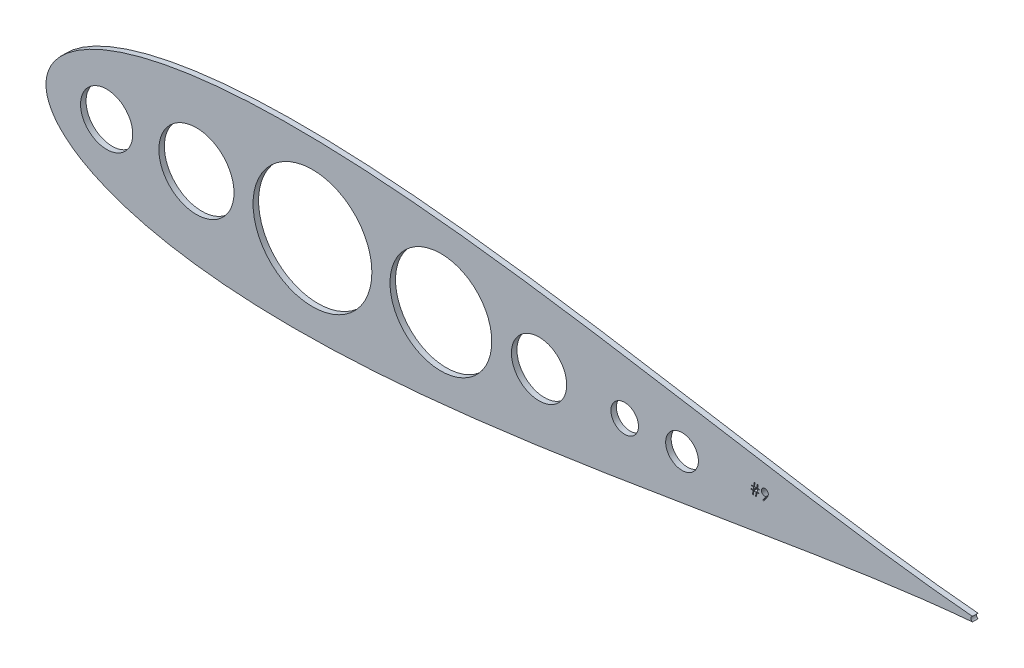
from build123d import *

# Parameters (mm, degrees)
SKETCH2_R           = 12.003328726
SKETCH2_R_2         = 17.272
SKETCH2_R_3         = 27.304154698
SKETCH2_R_4         = 12.7
SKETCH2_R_5         = 7.526838105
SKETCH2_R_6         = 23.387800821
SKETCH2_R_7         = 6.35
BOSS_EXTRUDE1_DEPTH = 2.54


with BuildPart() as part:
    # Sketch2 → Boss-Extrude1 (new body)
    with BuildSketch(Plane.XY):
        with BuildLine():
            ThreePointArc((721.354709246, 563.33473003), (720.664634471, 562.220490005), (721.354709164, 561.106249929))
            add(Edge.make_bspline(
                [(721.354709246, 563.33473003), (720.669692128, 563.393661196), (719.283144387, 563.512941923), (717.179502943, 563.704905159), (715.027025729, 563.90900958), (712.825783827, 564.126093988), (710.575758231, 564.355937385), (706.816173491, 564.752730715), (701.451746769, 565.353515459), (694.611641723, 566.17803442), (687.669543632, 567.066243813), (678.497434992, 568.299284095), (666.994604048, 569.944222298), (653.26960095, 572.025447015), (639.557989811, 574.192909916), (625.85603071, 576.420352413), (614.442731232, 578.306960032), (605.313315652, 579.823603062), (596.184134769, 581.341659683), (584.772034179, 583.235482757), (571.073189885, 585.481952879), (557.366871201, 587.68247387), (543.650085035, 589.817125434), (525.343636022, 592.548236847), (502.421039839, 595.694461701), (474.836201309, 598.858990536), (451.667984887, 600.818812639), (433.185336367, 601.827187361), (419.187067889, 602.27046729), (405.413344751, 602.343292613), (391.385257397, 601.985991161), (377.647895216, 601.138657859), (363.838593872, 599.682584455), (352.552004552, 597.895769847), (343.494210044, 595.987903541), (336.689585596, 594.276306338), (330.040008497, 592.273356885), (323.508731255, 589.911143108), (317.209877304, 587.155866841), (311.0979694, 583.845675073), (306.300201721, 580.509163904), (302.835763518, 577.42997479), (300.444363396, 574.850013906), (298.414638984, 572.067046924), (296.793248106, 568.981208199), (295.737048443, 565.694544149), (295.36198951, 562.220483166), (295.737047864, 558.746421775), (296.793198608, 555.459920072), (298.414537993, 552.374058948), (300.444151859, 549.591214855), (302.835635987, 547.011105672), (306.300065014, 543.931901204), (311.097968499, 540.595290519), (317.209877471, 537.285099341), (323.508575381, 534.529892024), (330.039845164, 532.16765923), (336.689420738, 530.164702152), (343.494209965, 528.453062476), (352.552004586, 526.545196377), (363.838426238, 524.758408925), (377.647725499, 523.302319133), (391.384918975, 522.454990818), (405.413175431, 522.097673158), (419.186730073, 522.170493332), (433.185167717, 522.613770204), (451.667816688, 523.622139936), (474.836201307, 525.581975454), (502.42103984, 528.746504551), (525.343636022, 531.892729341), (543.650085035, 534.623840763), (557.366871201, 536.758492326), (571.073189885, 538.959013316), (584.772034179, 541.205483439), (596.184134769, 543.099306512), (605.313315652, 544.617363134), (614.442731233, 546.134006161), (625.856030709, 548.020613797), (639.557989817, 550.248056224), (653.269600928, 552.415519387), (666.994604131, 554.496743125), (678.497267747, 556.141660506), (687.669376806, 557.374696374), (694.611305207, 558.26290404), (701.451584715, 559.087377696), (707.565162566, 559.772282801), (712.775750453, 560.313299347), (717.129309465, 560.737338789), (719.96825343, 560.985191328), (721.354709164, 561.106249929)],
                knots=[0, 0, 0, 0, 0.002325587, 0.004707236, 0.007144984, 0.009638866, 0.012188915, 0.01479516, 0.022426062, 0.030446954, 0.038098675, 0.046098559, 0.061750003, 0.077401464, 0.093052937, 0.108704411, 0.124355886, 0.132181624, 0.140007361, 0.155658837, 0.171310313, 0.18696179, 0.202613269, 0.21826475, 0.249567375, 0.280869705, 0.312171541, 0.328194705, 0.343474536, 0.359539212, 0.374777419, 0.390931321, 0.406079866, 0.4217306, 0.429556884, 0.437383358, 0.445456953, 0.45303644, 0.460863027, 0.46868956, 0.476515268, 0.480563979, 0.4843468, 0.48839404, 0.492178497, 0.496091162, 0.500000012, 0.503908862, 0.507821527, 0.511605415, 0.515653224, 0.519435473, 0.523484757, 0.531310465, 0.539136998, 0.546963585, 0.554542496, 0.562616667, 0.570443141, 0.578269425, 0.593920159, 0.60906813, 0.625222606, 0.640460241, 0.65652549, 0.671804749, 0.687828484, 0.719130321, 0.750432651, 0.781735275, 0.797386757, 0.813038235, 0.828689712, 0.844341188, 0.859992664, 0.867818402, 0.875644139, 0.891295615, 0.906947089, 0.922598561, 0.938250023, 0.953901466, 0.96190078, 0.969553071, 0.977573392, 0.985204866, 0.990360955, 0.995292577, 1, 1, 1, 1], degree=3))
        make_face()
        with Locations((323.360928395, 562.220483096)):
            Circle(SKETCH2_R, mode=Mode.SUBTRACT)
        with Locations((364.635928395, 562.220483096)):
            Circle(SKETCH2_R_2, mode=Mode.SUBTRACT)
        with Locations((417.973926997, 562.220483096)):
            Circle(SKETCH2_R_3, mode=Mode.SUBTRACT)
        with Locations((522.115928395, 562.220483096)):
            Circle(SKETCH2_R_4, mode=Mode.SUBTRACT)
        with Locations((587.849852492, 562.220483096)):
            Circle(SKETCH2_R_5, mode=Mode.SUBTRACT)
        with Locations((476.993270406, 562.220483096)):
            Circle(SKETCH2_R_6, mode=Mode.SUBTRACT)
        with Locations((561.485928395, 562.220483096)):
            Circle(SKETCH2_R_7, mode=Mode.SUBTRACT)
        Polygon((623.286299973, 563.411569166), (623.286299973, 563.085928141), (622.315482661, 563.085928141), (622.05191696, 561.327466594), (621.658094847, 561.327466594), (621.921660548, 563.085928141), (620.882662149, 563.085928141), (620.619096448, 561.327466594), (620.225274335, 561.327466594), (620.488840036, 563.085928141), (619.639120486, 563.085928141), (619.639120486, 563.411569166), (620.537686187, 563.411569166), (620.713735873, 564.583876855), (619.769376898, 564.583876855), (619.769376898, 564.90951788), (620.762582023, 564.90951788), (621.006812797, 566.537723006), (621.399617274, 566.537723006), (621.155386511, 564.90951788), (622.195402536, 564.90951788), (622.43963331, 566.537723006), (622.832437797, 566.537723006), (622.588207023, 564.90951788), (623.416556385, 564.90951788), (623.416556385, 564.583876855), (622.539360873, 564.583876855), (622.364328822, 563.411569166), align=None, mode=Mode.SUBTRACT)
        Polygon((625.370402536, 561.197210192), (625.006091636, 561.450599606), (626.418559586, 563.515367242), (626.147870486, 563.486873654), (625.884304774, 563.476697367), (625.724537149, 563.483820767), (625.571892923, 563.50417333), (625.424336835, 563.537755056), (625.283904136, 563.585583581), (625.148559586, 563.64664128), (625.020338435, 563.720928141), (624.897205423, 563.809461792), (624.78119581, 563.911224606), (624.675362473, 564.023163717), (624.58275831, 564.141208581), (624.505418561, 564.265359229), (624.441307986, 564.396633267), (624.392461835, 564.532995443), (624.356844847, 564.676481018), (624.335474649, 564.826072367), (624.328351249, 564.98176948), (624.341580423, 565.19445378), (624.380250297, 565.395944166), (624.445378498, 565.587258267), (624.53594741, 565.767378455), (624.650939398, 565.93426948), (624.787301574, 566.082843204), (624.946051574, 566.214117242), (625.126171762, 566.328091594), (625.320538749, 566.419678141), (625.522029136, 566.485823968), (625.730642923, 566.524493842), (625.945362473, 566.537723006), (626.156011511, 566.524493842), (626.358519523, 566.486841594), (626.552886511, 566.422731018), (626.739112473, 566.333179742), (626.912109262, 566.220223006), (627.064753498, 566.087931342), (627.198062797, 565.93426948), (627.312037149, 565.760255056), (627.402606061, 565.574029094), (627.467734262, 565.380679742), (627.506404136, 565.182242242), (627.51963331, 564.976681342), (627.511492274, 564.816913717), (627.488086835, 564.654093204), (627.447381699, 564.486184543), (627.391412149, 564.315223006), (627.356812797, 564.226689355), (627.315090036, 564.134085192), (627.267261511, 564.03639288), (627.213327212, 563.935647692), (627.153287149, 563.828796729), (627.087141322, 563.71889288), (627.013872086, 563.603900893), (626.934497086, 563.484838393), align=None, mode=Mode.SUBTRACT)
    extrude(amount=BOSS_EXTRUDE1_DEPTH)


solid = part.part
